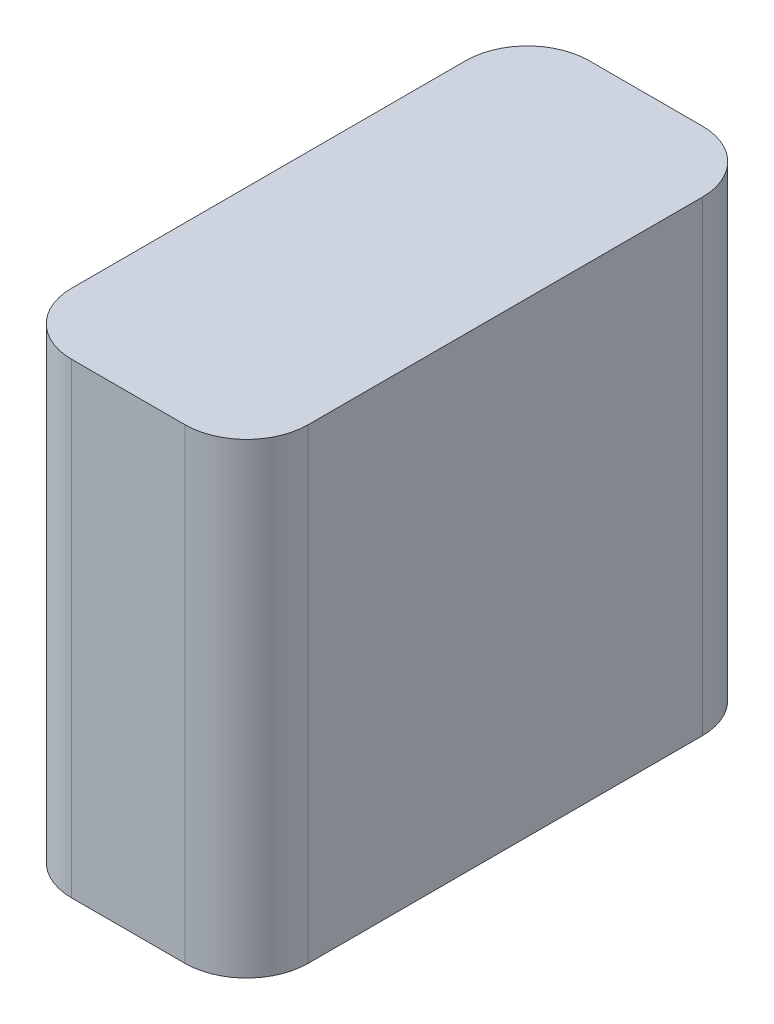
from build123d import *

# Parameters (mm, degrees)
BOSS_EXTRUDE1_DEPTH = 56.7436


with BuildPart() as part:
    # Sketch1 → Boss-Extrude1 (new body)
    with BuildSketch(Plane(origin=(0, 0, 0), x_dir=(1, 0, 0), z_dir=(0, 1, 0))):
        with BuildLine():
            Line((7.49935, 0), (21.26615, 0))
            ThreePointArc((21.26615, 0), (26.568991239, -2.196508761), (28.7655, -7.49935))
            Line((28.7655, -7.49935), (28.7655, -55.42915))
            ThreePointArc((28.7655, -55.42915), (26.568991239, -60.731991239), (21.26615, -62.9285))
            Line((21.26615, -62.9285), (7.49935, -62.9285))
            ThreePointArc((7.49935, -62.9285), (2.196508761, -60.731991239), (0, -55.42915))
            Line((0, -55.42915), (0, -7.49935))
            ThreePointArc((0, -7.49935), (2.196508761, -2.196508761), (7.49935, 0))
        make_face()
    extrude(amount=BOSS_EXTRUDE1_DEPTH)


solid = part.part
